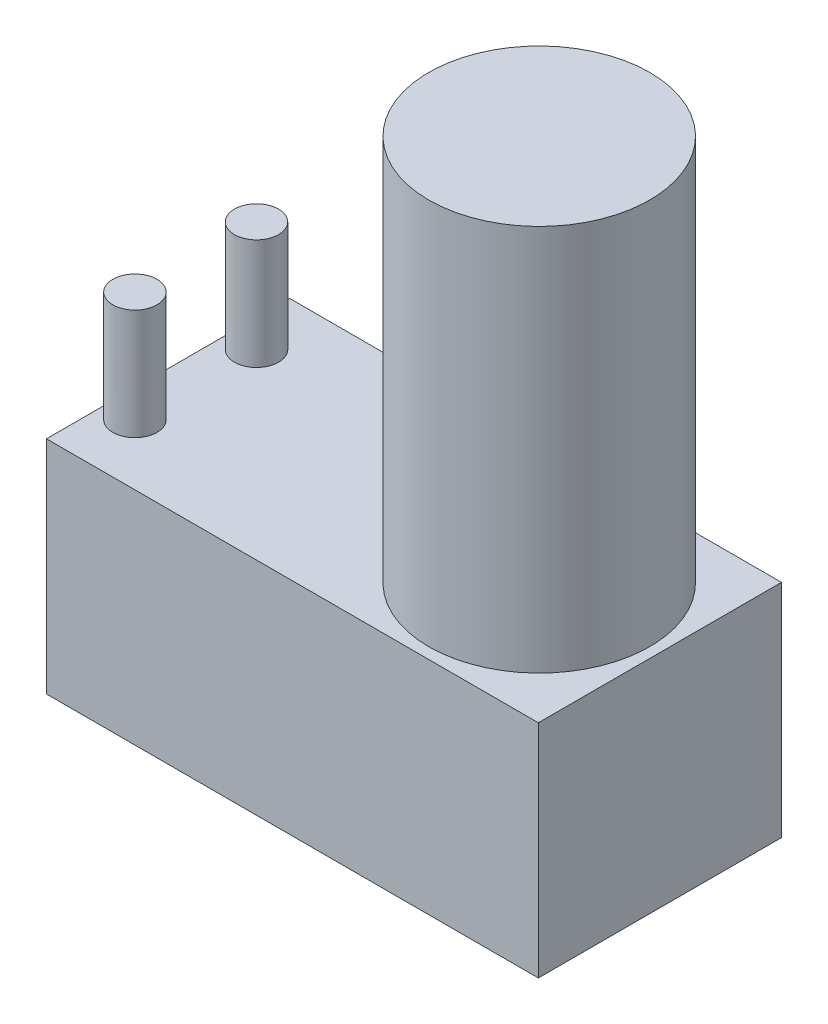
from build123d import *

# Parameters (mm, degrees)
SKETCH3_W           = 89
SKETCH3_H           = 44
BOSS_EXTRUDE1_DEPTH = 40
SKETCH4_R           = 20
BOSS_EXTRUDE2_DEPTH = 70
SKETCH5_R           = 4
BOSS_EXTRUDE3_DEPTH = 20


with BuildPart() as part:
    # Sketch3 → Boss-Extrude1 (new body)
    with BuildSketch(Plane(origin=(0, 0, 0), x_dir=(1, 0, 0), z_dir=(0, 1, 0))):
        Rectangle(SKETCH3_W, SKETCH3_H)
    extrude(amount=BOSS_EXTRUDE1_DEPTH)

    # Sketch4 → Boss-Extrude2 (add)
    with BuildSketch(Plane(origin=(0, 40, 0), x_dir=(1, 0, 0), z_dir=(0, 1, 0))):
        with Locations((22.662485516, 0)):
            Circle(SKETCH4_R)
    extrude(amount=BOSS_EXTRUDE2_DEPTH)

    # Sketch5 → Boss-Extrude3 (add)
    with BuildSketch(Plane(origin=(0, 40, 0), x_dir=(1, 0, 0), z_dir=(0, 1, 0))):
        with Locations((-39.5, -11)):
            Circle(SKETCH5_R)
        with Locations((-39.5, 11)):
            Circle(SKETCH5_R)
    extrude(amount=BOSS_EXTRUDE3_DEPTH)


solid = part.part
